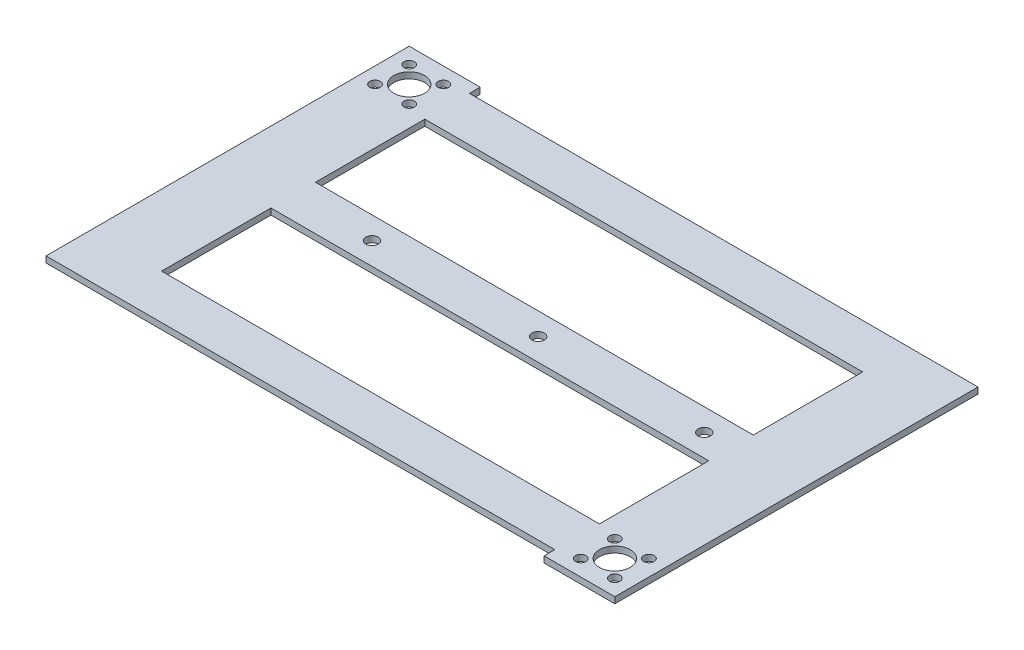
from build123d import *

# Parameters (mm, degrees)
SKETCH1_R           = 5
SKETCH1_R_2         = 1.7
SKETCH1_R_3         = 2
SKETCH1_W           = 142.3736446
SKETCH1_H           = 35.551129401
SKETCH1_H_2         = 35.551129402
BOSS_EXTRUDE1_DEPTH = 2


with BuildPart() as part:
    # Sketch1 → Boss-Extrude1 (new body)
    with BuildSketch(Plane(origin=(0, 0, 0), x_dir=(1, 0, 0), z_dir=(0, 1, 0))):
        Polygon((67.730491212, 150.133829438), (82.230491212, 150.133829438), (85.730491212, 150.133829438), (85.730491212, 100.082700036), (85.730491212, 85.582700036), (85.730491212, 50.031570635), (85.730491212, 32.031570635), (67.730491212, 32.031570635), (62.730491212, 32.031570635), (62.730491212, 35.531570635), (-84.727026002, 35.531570635), (-99.227026002, 35.531570635), (-102.727026002, 35.531570635), (-102.727026002, 85.582700036), (-102.727026002, 92.832700036), (-102.727026002, 98.923608877), (-102.727026002, 100.082700036), (-102.727026002, 153.633829438), (-84.643153388, 153.633829438), (-79.643153388, 153.633829438), (-79.643153388, 153.432122466), (-79.643153388, 150.133829438), align=None)
        with Locations((-91.977026002, 142.883829438)):
            Circle(SKETCH1_R, mode=Mode.SUBTRACT)
        with Locations((74.980491212, 42.781570635)):
            Circle(SKETCH1_R, mode=Mode.SUBTRACT)
        with Locations((-86.427026002, 148.433829438)):
            Circle(SKETCH1_R_2, mode=Mode.SUBTRACT)
        with Locations((-97.527026002, 148.433829438)):
            Circle(SKETCH1_R_2, mode=Mode.SUBTRACT)
        with Locations((-86.427026002, 137.333829438)):
            Circle(SKETCH1_R_2, mode=Mode.SUBTRACT)
        with Locations((-97.527026002, 137.333829438)):
            Circle(SKETCH1_R_2, mode=Mode.SUBTRACT)
        with Locations((69.430491212, 48.331570635)):
            Circle(SKETCH1_R_2, mode=Mode.SUBTRACT)
        with Locations((80.530491212, 48.331570635)):
            Circle(SKETCH1_R_2, mode=Mode.SUBTRACT)
        with Locations((80.530491212, 37.231570635)):
            Circle(SKETCH1_R_2, mode=Mode.SUBTRACT)
        with Locations((69.430491212, 37.231570635)):
            Circle(SKETCH1_R_2, mode=Mode.SUBTRACT)
        with Locations((-54, 92.833829438)):
            Circle(SKETCH1_R_3, mode=Mode.SUBTRACT)
        with Locations((0, 92.833829438)):
            Circle(SKETCH1_R_3, mode=Mode.SUBTRACT)
        with Locations((54, 92.833829438)):
            Circle(SKETCH1_R_3, mode=Mode.SUBTRACT)
        with Locations((-8.456331088, 67.807135336)):
            Rectangle(SKETCH1_W, SKETCH1_H, mode=Mode.SUBTRACT)
        with Locations((-8.456331088, 117.858264737)):
            Rectangle(SKETCH1_W, SKETCH1_H_2, mode=Mode.SUBTRACT)
    extrude(amount=BOSS_EXTRUDE1_DEPTH)


solid = part.part
